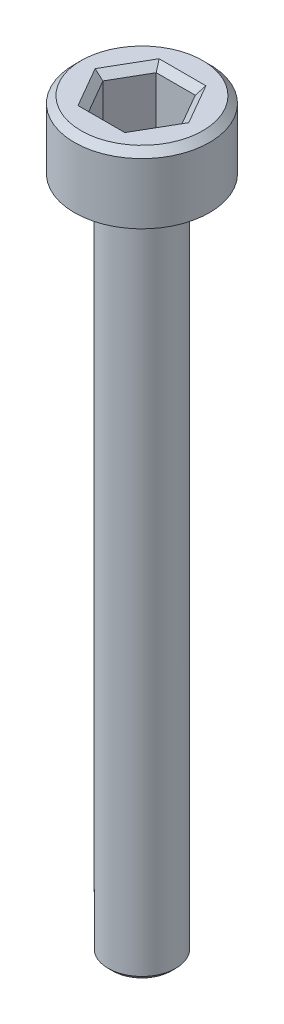
from build123d import *

# Parameters (mm, degrees)
SKETCH1_R           = 3
BOSS_EXTRUDE1_DEPTH = 3
CHAMFER1_SIZE       = 0.3
CUT_EXTRUDE1_DEPTH  = 2.5
CHAMFER2_SIZE       = 0.3
SKETCH3_R           = 1.5
BOSS_EXTRUDE2_DEPTH = 30
CHAMFER3_SIZE       = 0.2


with BuildPart() as part:
    # Sketch1 → Boss-Extrude1 (new body)
    with BuildSketch(Plane(origin=(0, 0, 0), x_dir=(1, 0, 0), z_dir=(0, 1, 0))):
        with Locations(Location((0, 0, 0), (0, 0, 270))):  # turned: the seam where the file's is
            Circle(SKETCH1_R)
    extrude(amount=BOSS_EXTRUDE1_DEPTH)

    # Chamfer1
    chamfer1_edges = [part.edges().sort_by_distance(p)[0] for p in [
        (0, 3, -3),
    ]]
    chamfer(chamfer1_edges, length=CHAMFER1_SIZE)

    # Sketch2 → Cut-Extrude1 (cut)
    with BuildSketch(Plane(origin=(0, 3, 0), x_dir=(1, 0, 0), z_dir=(0, 1, 0))):
        Polygon((1.732050808, 0), (0.866025404, 1.5), (-0.866025404, 1.5), (-1.732050808, 0), (-0.866025404, -1.5), (0.866025404, -1.5), align=None)
    extrude(amount=-CUT_EXTRUDE1_DEPTH, mode=Mode.SUBTRACT)

    # Chamfer2
    chamfer2_edges = [part.edges().sort_by_distance(p)[0] for p in [
        (1.299038106, 3, 0.75),
        (1.299038106, 3, -0.75),
        (0, 3, -1.5),
        (-1.299038106, 3, -0.75),
        (-1.299038106, 3, 0.75),
        (0, 3, 1.5),
    ]]
    chamfer(chamfer2_edges, length=CHAMFER2_SIZE)

    # Sketch3 → Boss-Extrude2 (add)
    with BuildSketch(Plane.XZ):
        with Locations(Location((0, 0, 0), (0, 0, 90))):  # turned: the seam where the file's is
            Circle(SKETCH3_R)
    extrude(amount=BOSS_EXTRUDE2_DEPTH)

    # Chamfer3
    chamfer3_edges = [part.edges().sort_by_distance(p)[0] for p in [
        (0, -30, -1.5),
    ]]
    chamfer(chamfer3_edges, length=CHAMFER3_SIZE)


solid = part.part
